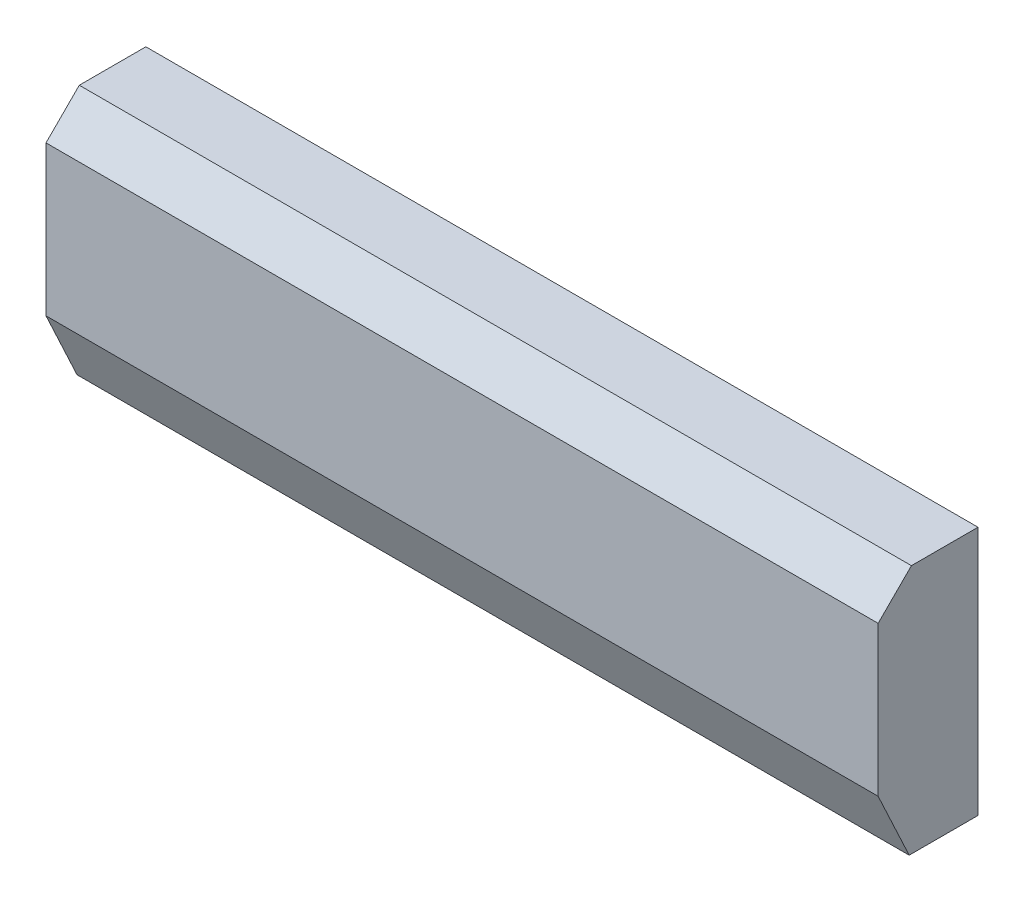
from build123d import *

# Parameters (mm, degrees)
SKETCH_1_W      = 25
SKETCH_1_H      = 7.5
EXTRUDE_1_DEPTH = 3
CHAMFER_1_SIZE  = 1
CHAMFER_2_SIZE  = 2
CHAMFER_2_SIZE2 = 0.932615316


with BuildPart() as part:
    # Эскиз1 → Вытянуть1 (new body)
    with BuildSketch(Plane.XY):
        with Locations((0, 0.25)):
            Rectangle(SKETCH_1_W, SKETCH_1_H)
    extrude(amount=EXTRUDE_1_DEPTH)

    # Фаска1
    chamfer_1_edges = [part.edges().sort_by_distance(p)[0] for p in [
        (0, 4, 3),
    ]]
    chamfer(chamfer_1_edges, length=CHAMFER_1_SIZE)

    # Фаска2
    chamfer_2_edges = [part.edges().sort_by_distance(p)[0] for p in [
        (0, -3.5, 3),
    ]]
    chamfer_2_side = [part.faces().sort_by_distance(p)[0] for p in [
        (0, -0.25, 3),
    ]]
    chamfer(chamfer_2_edges, length=CHAMFER_2_SIZE, length2=CHAMFER_2_SIZE2, reference=chamfer_2_side[0])


solid = part.part
